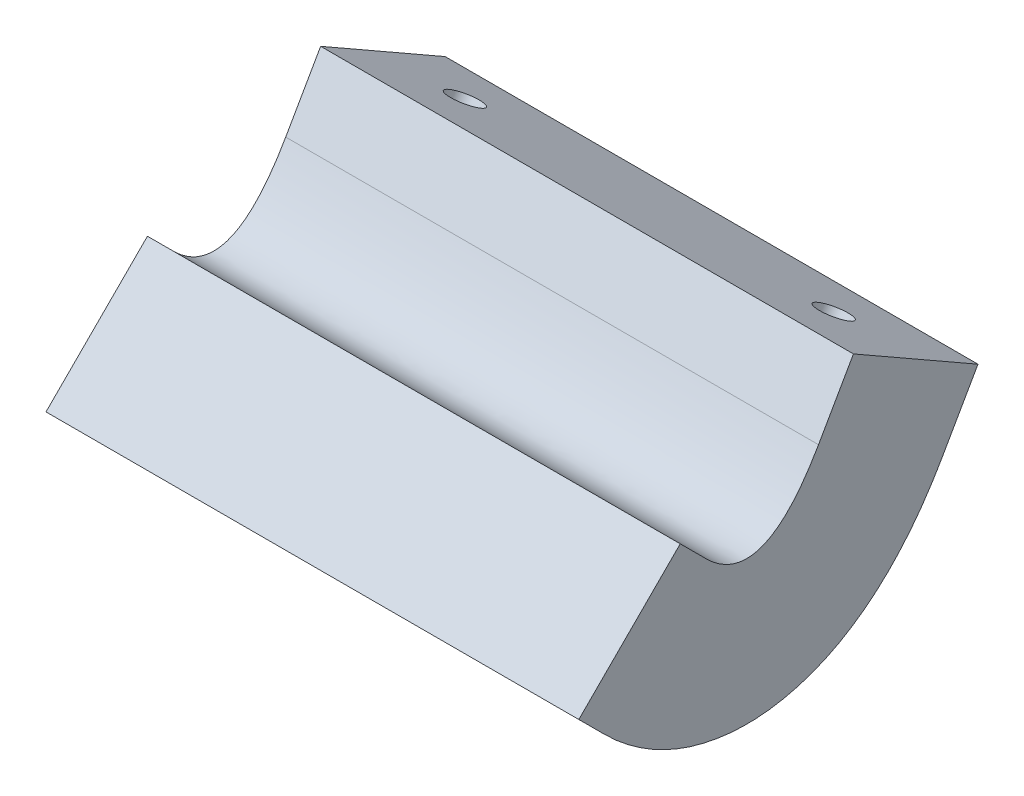
from build123d import *

# Parameters (mm, degrees)
BOSS_EXTRUDE1_DEPTH = 26
SKETCH3_R           = 0.8
CUT_EXTRUDE1_DEPTH  = 7


with BuildPart() as part:
    # Sketch1 → Boss-Extrude1 (new body)
    with BuildSketch(Plane(origin=(0, 0, 0), x_dir=(0, 0, -1), z_dir=(1, 0, 0))):
        with BuildLine():
            Line((3.5, 3.0625), (5.205065915, 6.046365351))
            Line((5.205065915, 6.046365351), (11.28276791, 2.573392782))
            Line((11.28276791, 2.573392782), (9.577701995, -0.410472568))
            add(Edge.make_bspline(
                [(-6.949747468, -3.949747468), (-6.685368266, -4.214126671), (-6.147554271, -4.708312104), (-4.8590745, -5.674523534), (-2.826984501, -6.712797376), (0.295880791, -7.18416331), (3.330320935, -6.524197206), (5.630020015, -5.201123324), (7.839744032, -3.168086519), (8.912819335, -1.574017223), (9.577701995, -0.410472568)],
                knots=[0.075491359, 0.075491359, 0.075491359, 0.075491359, 0.129884041, 0.184276723, 0.293062086, 0.401847449, 0.510632813, 0.619418176, 0.72820354, 0.945774267, 0.945774267, 0.945774267, 0.945774267], degree=3))
            Line((-6.949747468, -3.949747468), (-8.196862299, -2.702632638))
            Line((-8.196862299, -2.702632638), (-3.24711483, 2.24711483))
            Line((-3.24711483, 2.24711483), (-2, 1))
            add(Edge.make_bspline(
                [(-2, 1), (0.75, -1.75), (3.5, 3.0625)],
                knots=[0.075491359, 0.075491359, 0.075491359, 0.945774267, 0.945774267, 0.945774267], degree=2))
        make_face()
    extrude(amount=BOSS_EXTRUDE1_DEPTH)

    # Sketch3 → Cut-Extrude1 (cut)
    with BuildSketch(Plane(origin=(0, 7.641933234, -2.41282212), x_dir=(1, 0, 0), z_dir=(0, 0.868243142, -0.496138938))):
        with Locations((4, 6.715969882)):
            Circle(SKETCH3_R)
        with Locations((22, 6.715969882)):
            Circle(SKETCH3_R)
    extrude(amount=-CUT_EXTRUDE1_DEPTH, mode=Mode.SUBTRACT)


solid = part.part
